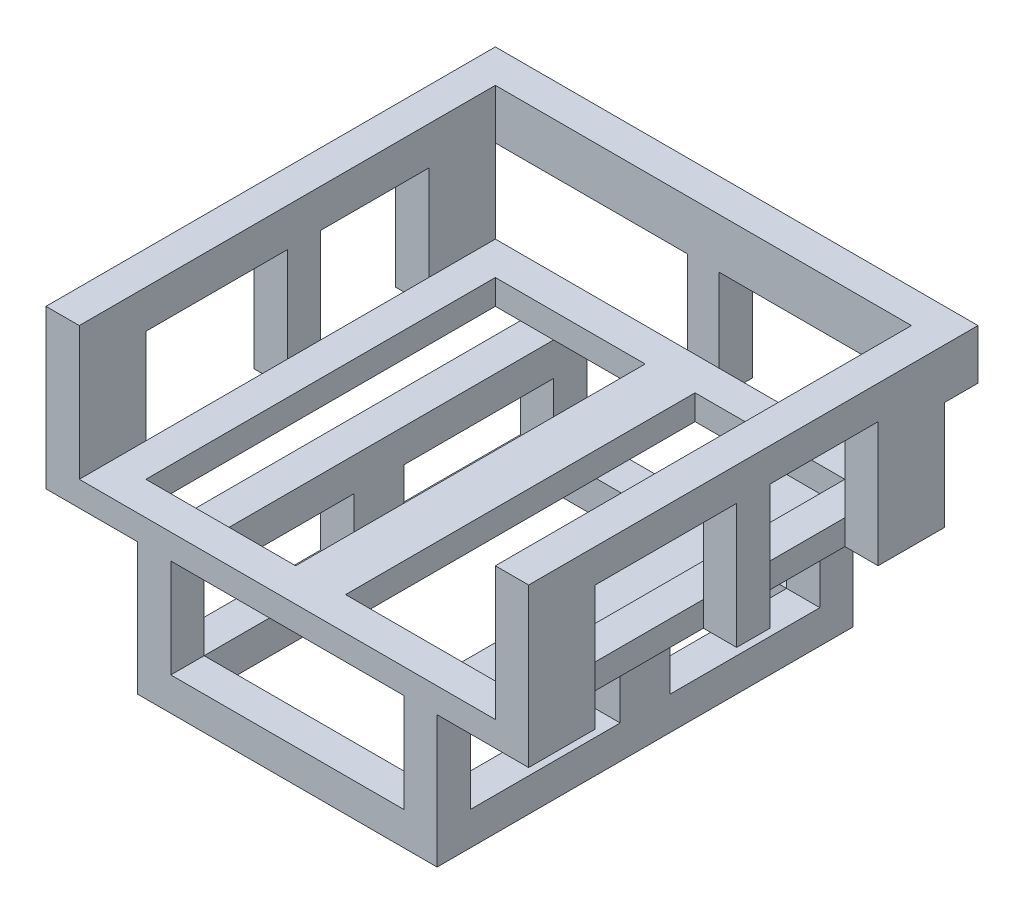
from build123d import *

# Parameters (mm, degrees)
SKETCH1_W            = 25
SKETCH1_H            = 25
SKETCH1_W_2          = 9
SKETCH1_H_2          = 21
BOSS_EXTRUDE1_DEPTH  = 1.5
BOSS_EXTRUDE2_DEPTH  = 2
BOSS_EXTRUDE3_DEPTH  = 2
BOSS_EXTRUDE8_DEPTH  = 2
SKETCH12_W           = 2
SKETCH12_H           = 25
BOSS_EXTRUDE10_DEPTH = 5.93
SKETCH11_W           = 18
SKETCH11_H           = 25
SKETCH11_W_2         = 14
SKETCH11_H_2         = 21
BOSS_EXTRUDE11_DEPTH = 2
SKETCH13_W           = 9
SKETCH13_H           = 3.93
CUT_EXTRUDE2_DEPTH   = 24.5


with BuildPart() as part:
    # Sketch1 → Boss-Extrude1 (new body)
    with BuildSketch(Plane(origin=(0, 0, 0), x_dir=(1, 0, 0), z_dir=(0, 1, 0))):
        with Locations((0, -1)):
            Rectangle(SKETCH1_W, SKETCH1_H)
        with Locations((-6, -1)):
            Rectangle(SKETCH1_W_2, SKETCH1_H_2, mode=Mode.SUBTRACT)
        with Locations((6, -1)):
            Rectangle(SKETCH1_W_2, SKETCH1_H_2, mode=Mode.SUBTRACT)
    extrude(amount=BOSS_EXTRUDE1_DEPTH)

    # Sketch2 → Boss-Extrude2 (add)
    with BuildSketch(Plane(origin=(12.5, 0, 0), x_dir=(0, 0, -1), z_dir=(1, 0, 0))):
        Polygon((-9.5, 7.5), (-1, 7.5), (-1, 0), (1, 0), (1, 7.5), (7.5, 7.5), (7.5, 0), (11.5, 0), (11.5, 9.5), (-13.5, 9.5), (-13.5, 0), (-9.5, 0), align=None)
    extrude(amount=BOSS_EXTRUDE2_DEPTH)

    # Sketch3 → Boss-Extrude3 (add)
    with BuildSketch(Plane.ZY.offset(12.5)):
        Polygon((1, 0), (1, 7.2), (9.5, 7.2), (9.5, 0), (13.5, 0), (13.5, 9.5), (-11.5, 9.5), (-11.5, 0), (-7.5, 0), (-7.5, 7.2), (-1, 7.2), (-1, 0), align=None)
    extrude(amount=BOSS_EXTRUDE3_DEPTH)

    # Sketch10 → Boss-Extrude8 (add)
    with BuildSketch(Plane(origin=(0, 0, -11.5), x_dir=(-1, 0, 0), z_dir=(0, 0, -1))):
        Polygon((14.5, 9.5), (-14.5, 9.5), (-14.5, 6.5), (-0.948009726, 6.5), (-0.948009726, 0), (0.95, 0), (0.95, 6.5), (14.5, 6.5), align=None)
    extrude(amount=BOSS_EXTRUDE8_DEPTH)

    # Sketch12 → Boss-Extrude10 (add)
    with BuildSketch(Plane(origin=(0, 0, 0), x_dir=(-1, 0, 0), z_dir=(0, -1, 0))):
        with Locations((-8, -1)):
            Rectangle(SKETCH12_W, SKETCH12_H)
        with Locations((8, -1)):
            Rectangle(SKETCH12_W, SKETCH12_H)
    extrude(amount=BOSS_EXTRUDE10_DEPTH)

    # Sketch11 → Boss-Extrude11 (add)
    with BuildSketch(Plane(origin=(0, -5.93, 0), x_dir=(-1, 0, 0), z_dir=(0, -1, 0))):
        with Locations((0, -1)):
            Rectangle(SKETCH11_W, SKETCH11_H)
        with Locations((0, -1)):
            Rectangle(SKETCH11_W_2, SKETCH11_H_2, mode=Mode.SUBTRACT)
    extrude(amount=BOSS_EXTRUDE11_DEPTH)

    # Sketch13 → Cut-Extrude2 (cut, through all)
    with BuildSketch(Plane.ZY.offset(9)):
        with Locations((-5, -3.965)):
            Rectangle(SKETCH13_W, SKETCH13_H)
        with Locations((7, -3.965)):
            Rectangle(SKETCH13_W, SKETCH13_H)
    extrude(amount=-CUT_EXTRUDE2_DEPTH, mode=Mode.SUBTRACT)


solid = part.part
